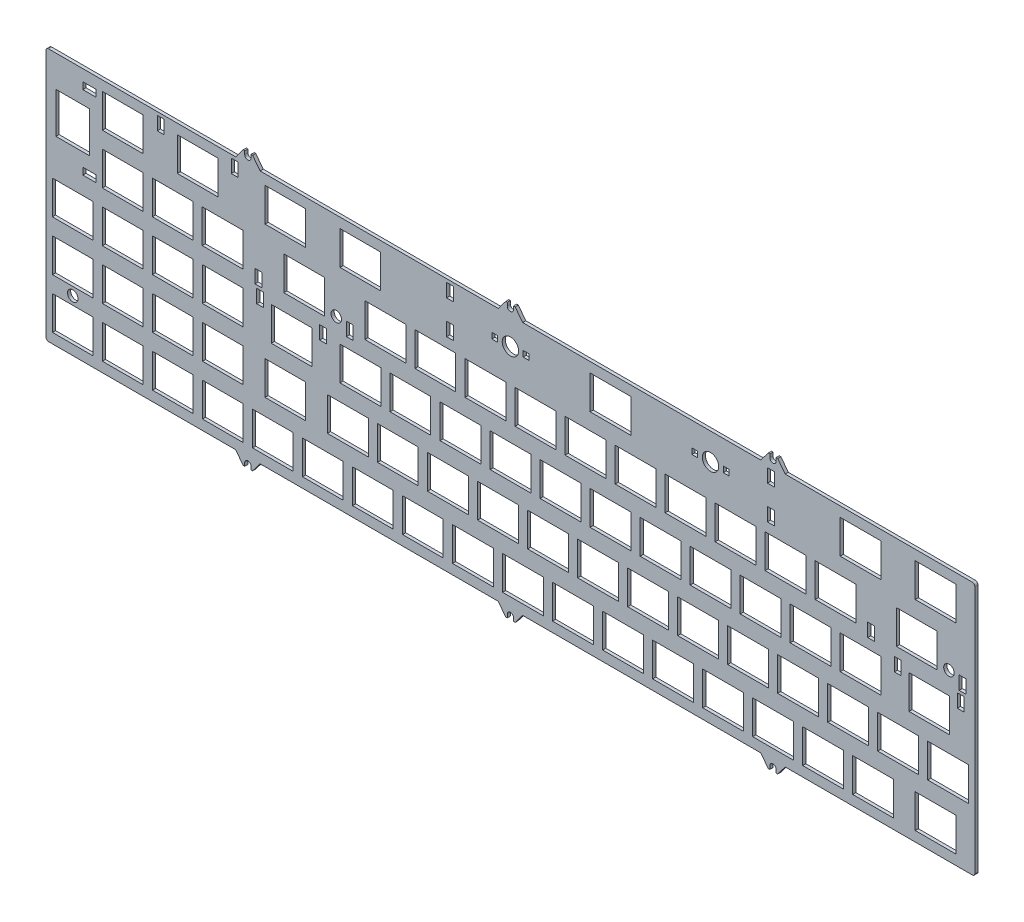
from build123d import *

# Parameters (mm, degrees)
SKETCH2_R           = 3.125
SKETCH2_R_2         = 2
SKETCH2_W           = 15.6
SKETCH2_H           = 12.8
SKETCH2_W_2         = 2.6
SKETCH2_H_2         = 5.1
SKETCH2_W_3         = 2.2
SKETCH2_H_3         = 2.2
SKETCH2_W_4         = 5.1
SKETCH2_H_4         = 2.6
SKETCH2_W_5         = 15.5
SKETCH2_W_6         = 12.8
SKETCH2_H_5         = 15.5
BOSS_EXTRUDE1_DEPTH = 1.2


with BuildPart() as part:
    # Sketch2 → Boss-Extrude1 (new body)
    with BuildSketch(Plane(origin=(0, 0, 0), x_dir=(1, 0, 0), z_dir=(0, 0, -1))):
        with BuildLine():
            Line((-4.122e-06, 4.749999815), (-4.122e-06, 99.349999815))
            ThreePointArc((-4.122e-06, 99.349999815), (0.292889097, 100.057106597), (0.999995878, 100.349999815))
            Line((0.999995878, 100.349999815), (72.237495878, 100.349999815))
            Line((72.237495878, 100.349999815), (75.087495878, 104.099999815))
            Line((75.087495878, 104.099999815), (75.687495878, 104.099999815))
            Line((75.687495878, 104.099999815), (75.687495878, 103.599999815))
            Line((75.687495878, 103.599999815), (75.687495878, 102.849999815))
            ThreePointArc((75.687495878, 102.849999815), (76.887495878, 101.649999815), (78.087495878, 102.849999815))
            Line((78.087495878, 102.849999815), (78.087495878, 103.599999815))
            Line((78.087495878, 103.599999815), (78.087495878, 104.099999815))
            Line((78.087495878, 104.099999815), (78.687495879, 104.099999815))
            Line((78.687495879, 104.099999815), (81.537495879, 100.349999815))
            Line((81.537495879, 100.349999815), (172.237495878, 100.349999815))
            Line((172.237495878, 100.349999815), (175.087495878, 104.099999815))
            Line((175.087495878, 104.099999815), (175.687495878, 104.099999815))
            Line((175.687495878, 104.099999815), (175.687495878, 102.849999815))
            ThreePointArc((175.687495878, 102.849999815), (176.887495878, 101.649999815), (178.087495878, 102.849999815))
            Line((178.087495878, 102.849999815), (178.087495878, 104.099999815))
            Line((178.087495878, 104.099999815), (178.687495878, 104.099999815))
            Line((178.687495878, 104.099999815), (181.537495878, 100.349999815))
            Line((181.537495878, 100.349999815), (272.237495878, 100.349999815))
            Line((272.237495878, 100.349999815), (275.087495878, 104.099999815))
            Line((275.087495878, 104.099999815), (275.687495878, 104.099999815))
            Line((275.687495878, 104.099999815), (275.687495878, 102.849999815))
            ThreePointArc((275.687495878, 102.849999815), (276.887495878, 101.649999815), (278.087495878, 102.849999815))
            Line((278.087495878, 102.849999815), (278.087495878, 104.099999815))
            Line((278.087495878, 104.099999815), (278.687495878, 104.099999815))
            Line((278.687495878, 104.099999815), (281.537495878, 100.349999815))
            Line((281.537495878, 100.349999815), (352.774995878, 100.349999815))
            ThreePointArc((352.774995878, 100.349999815), (353.48210266, 100.057106597), (353.774995878, 99.349999815))
            Line((353.774995878, 99.349999815), (353.774995878, 4.749999815))
            ThreePointArc((353.774995878, 4.749999815), (353.48210266, 4.042893034), (352.774995878, 3.749999815))
            Line((352.774995878, 3.749999815), (281.537495878, 3.749999815))
            Line((281.537495878, 3.749999815), (278.687495878, -1.85e-07))
            Line((278.687495878, -1.85e-07), (278.087495878, -1.85e-07))
            Line((278.087495878, -1.85e-07), (278.087495878, 1.249999815))
            ThreePointArc((278.087495878, 1.249999815), (276.887495878, 2.449999815), (275.687495878, 1.249999815))
            Line((275.687495878, 1.249999815), (275.687495878, -1.85e-07))
            Line((275.687495878, -1.85e-07), (275.087495878, -1.85e-07))
            Line((275.087495878, -1.85e-07), (272.237495878, 3.749999815))
            Line((272.237495878, 3.749999815), (181.537495878, 3.749999815))
            Line((181.537495878, 3.749999815), (178.687495878, -1.85e-07))
            Line((178.687495878, -1.85e-07), (178.087495878, -1.85e-07))
            Line((178.087495878, -1.85e-07), (178.087495878, 1.249999815))
            ThreePointArc((178.087495878, 1.249999815), (176.887495878, 2.449999815), (175.687495878, 1.249999815))
            Line((175.687495878, 1.249999815), (175.687495878, -1.85e-07))
            Line((175.687495878, -1.85e-07), (175.087495878, -1.85e-07))
            Line((175.087495878, -1.85e-07), (172.237495878, 3.749999815))
            Line((172.237495878, 3.749999815), (81.537495879, 3.749999815))
            Line((81.537495879, 3.749999815), (78.687495879, -1.85e-07))
            Line((78.687495879, -1.85e-07), (78.087495878, -1.85e-07))
            Line((78.087495878, -1.85e-07), (78.087495878, 0.499999815))
            Line((78.087495878, 0.499999815), (78.087495878, 1.249999815))
            ThreePointArc((78.087495878, 1.249999815), (76.887495878, 2.449999815), (75.687495878, 1.249999815))
            Line((75.687495878, 1.249999815), (75.687495878, 0.499999815))
            Line((75.687495878, 0.499999815), (75.687495878, -1.85e-07))
            Line((75.687495878, -1.85e-07), (75.087495878, -1.85e-07))
            Line((75.087495878, -1.85e-07), (72.237495878, 3.749999815))
            Line((72.237495878, 3.749999815), (0.999995878, 3.749999815))
            ThreePointArc((0.999995878, 3.749999815), (0.292889097, 4.042893034), (-4.122e-06, 4.749999815))
        make_face()
        with Locations((176.887495878, 13.949999815)):
            Circle(SKETCH2_R, mode=Mode.SUBTRACT)
        with Locations((253.087495878, 13.949999815)):
            Circle(SKETCH2_R, mode=Mode.SUBTRACT)
        with Locations((343.918745878, 37.249999815)):
            Circle(SKETCH2_R_2, mode=Mode.SUBTRACT)
        with Locations((110.556245878, 37.249999815)):
            Circle(SKETCH2_R_2, mode=Mode.SUBTRACT)
        with Locations((10.199995878, 80.624999815)):
            Circle(SKETCH2_R_2, mode=Mode.SUBTRACT)
        with Locations((129.262495878, 32.999999815)):
            Rectangle(SKETCH2_W, SKETCH2_H, mode=Mode.SUBTRACT)
        with Locations((119.737495878, 52.049999815)):
            Rectangle(SKETCH2_W, SKETCH2_H, mode=Mode.SUBTRACT)
        with Locations((114.974995878, 71.099999815)):
            Rectangle(SKETCH2_W, SKETCH2_H, mode=Mode.SUBTRACT)
        with Locations((324.431248691, 45.649999553)):
            Rectangle(SKETCH2_W_2, SKETCH2_H_2, mode=Mode.SUBTRACT)
        with Locations((348.431245878, 45.649999815)):
            Rectangle(SKETCH2_W_2, SKETCH2_H_2, mode=Mode.SUBTRACT)
        with Locations((105.543745878, 45.649999815)):
            Rectangle(SKETCH2_W_2, SKETCH2_H_2, mode=Mode.SUBTRACT)
        with Locations((314.268745878, 39.399999815)):
            Rectangle(SKETCH2_W_2, SKETCH2_H_2, mode=Mode.SUBTRACT)
        with Locations((349.068745878, 39.399999815)):
            Rectangle(SKETCH2_W_2, SKETCH2_H_2, mode=Mode.SUBTRACT)
        with Locations((115.706245878, 39.399999815)):
            Rectangle(SKETCH2_W_2, SKETCH2_H_2, mode=Mode.SUBTRACT)
        with Locations((153.887495878, 7.549999815)):
            Rectangle(SKETCH2_W_2, SKETCH2_H_2, mode=Mode.SUBTRACT)
        with Locations((182.862495878, 13.949999815)):
            Rectangle(SKETCH2_W_3, SKETCH2_H_3, mode=Mode.SUBTRACT)
        with Locations((170.912495878, 13.949999815)):
            Rectangle(SKETCH2_W_3, SKETCH2_H_3, mode=Mode.SUBTRACT)
        with Locations((247.112495878, 13.949999815)):
            Rectangle(SKETCH2_W_3, SKETCH2_H_3, mode=Mode.SUBTRACT)
        with Locations((259.062495878, 13.949999815)):
            Rectangle(SKETCH2_W_3, SKETCH2_H_3, mode=Mode.SUBTRACT)
        with Locations((81.543748691, 45.649999553)):
            Rectangle(SKETCH2_W_2, SKETCH2_H_2, mode=Mode.SUBTRACT)
        with Locations((80.906245878, 39.399999815)):
            Rectangle(SKETCH2_W_2, SKETCH2_H_2, mode=Mode.SUBTRACT)
        with Locations((43.674995878, 7.549999815)):
            Rectangle(SKETCH2_W_2, SKETCH2_H_2, mode=Mode.SUBTRACT)
        with Locations((71.874995878, 7.549999815)):
            Rectangle(SKETCH2_W_2, SKETCH2_H_2, mode=Mode.SUBTRACT)
        with Locations((16.574995878, 9.374999815)):
            Rectangle(SKETCH2_W_4, SKETCH2_H_4, mode=Mode.SUBTRACT)
        with Locations((16.574995878, 37.574999815)):
            Rectangle(SKETCH2_W_4, SKETCH2_H_4, mode=Mode.SUBTRACT)
        with Locations((153.887495878, 20.349999815)):
            Rectangle(SKETCH2_W_2, SKETCH2_H_2, mode=Mode.SUBTRACT)
        with Locations((276.087495878, 20.349999815)):
            Rectangle(SKETCH2_W_2, SKETCH2_H_2, mode=Mode.SUBTRACT)
        with Locations((276.087495878, 7.549999815)):
            Rectangle(SKETCH2_W_2, SKETCH2_H_2, mode=Mode.SUBTRACT)
        with Locations((338.812495878, 90.149999815)):
            Rectangle(SKETCH2_W_5, SKETCH2_H, mode=Mode.SUBTRACT)
        with Locations((314.999995878, 90.149999815)):
            Rectangle(SKETCH2_W_5, SKETCH2_H, mode=Mode.SUBTRACT)
        with Locations((295.949995878, 90.149999815)):
            Rectangle(SKETCH2_W_5, SKETCH2_H, mode=Mode.SUBTRACT)
        with Locations((276.899995878, 90.149999815)):
            Rectangle(SKETCH2_W_5, SKETCH2_H, mode=Mode.SUBTRACT)
        with Locations((257.849995878, 90.149999815)):
            Rectangle(SKETCH2_W_5, SKETCH2_H, mode=Mode.SUBTRACT)
        with Locations((238.799995878, 90.149999815)):
            Rectangle(SKETCH2_W_5, SKETCH2_H, mode=Mode.SUBTRACT)
        with Locations((219.749995878, 90.149999815)):
            Rectangle(SKETCH2_W_5, SKETCH2_H, mode=Mode.SUBTRACT)
        with Locations((200.699995878, 90.149999815)):
            Rectangle(SKETCH2_W_5, SKETCH2_H, mode=Mode.SUBTRACT)
        with Locations((181.649995878, 90.149999815)):
            Rectangle(SKETCH2_W_5, SKETCH2_H, mode=Mode.SUBTRACT)
        with Locations((162.599995878, 90.149999815)):
            Rectangle(SKETCH2_W_5, SKETCH2_H, mode=Mode.SUBTRACT)
        with Locations((143.549995878, 90.149999815)):
            Rectangle(SKETCH2_W_5, SKETCH2_H, mode=Mode.SUBTRACT)
        with Locations((124.499995878, 90.149999815)):
            Rectangle(SKETCH2_W_5, SKETCH2_H, mode=Mode.SUBTRACT)
        with Locations((105.449995878, 90.149999815)):
            Rectangle(SKETCH2_W_5, SKETCH2_H, mode=Mode.SUBTRACT)
        with Locations((86.399995878, 90.149999815)):
            Rectangle(SKETCH2_W_5, SKETCH2_H, mode=Mode.SUBTRACT)
        with Locations((67.349995878, 71.099999815)):
            Rectangle(SKETCH2_W_5, SKETCH2_H, mode=Mode.SUBTRACT)
        with Locations((67.349995878, 90.149999815)):
            Rectangle(SKETCH2_W_5, SKETCH2_H, mode=Mode.SUBTRACT)
        with Locations((48.299995878, 71.099999815)):
            Rectangle(SKETCH2_W_5, SKETCH2_H, mode=Mode.SUBTRACT)
        with Locations((48.299995878, 90.149999815)):
            Rectangle(SKETCH2_W_5, SKETCH2_H, mode=Mode.SUBTRACT)
        with Locations((29.249995878, 71.099999815)):
            Rectangle(SKETCH2_W_5, SKETCH2_H, mode=Mode.SUBTRACT)
        with Locations((29.249995878, 90.149999815)):
            Rectangle(SKETCH2_W_5, SKETCH2_H, mode=Mode.SUBTRACT)
        with Locations((10.199995878, 71.099999815)):
            Rectangle(SKETCH2_W_5, SKETCH2_H, mode=Mode.SUBTRACT)
        with Locations((10.199995878, 90.149999815)):
            Rectangle(SKETCH2_W_5, SKETCH2_H, mode=Mode.SUBTRACT)
        with Locations((67.299995878, 52.049999815)):
            Rectangle(SKETCH2_W_5, SKETCH2_H, mode=Mode.SUBTRACT)
        with Locations((48.249995878, 52.049999815)):
            Rectangle(SKETCH2_W_5, SKETCH2_H, mode=Mode.SUBTRACT)
        with Locations((29.199995878, 52.049999815)):
            Rectangle(SKETCH2_W_5, SKETCH2_H, mode=Mode.SUBTRACT)
        with Locations((10.149995878, 52.049999815)):
            Rectangle(SKETCH2_W_5, SKETCH2_H, mode=Mode.SUBTRACT)
        with Locations((48.249995878, 32.999999815)):
            Rectangle(SKETCH2_W_5, SKETCH2_H, mode=Mode.SUBTRACT)
        with Locations((29.199995878, 32.999999815)):
            Rectangle(SKETCH2_W_5, SKETCH2_H, mode=Mode.SUBTRACT)
        with Locations((29.199995878, 13.949999815)):
            Rectangle(SKETCH2_W_5, SKETCH2_H, mode=Mode.SUBTRACT)
        with Locations((57.774995878, 13.949999815)):
            Rectangle(SKETCH2_W_5, SKETCH2_H, mode=Mode.SUBTRACT)
        with Locations((91.162495878, 13.949999815)):
            Rectangle(SKETCH2_W_5, SKETCH2_H, mode=Mode.SUBTRACT)
        with Locations((119.737495878, 13.949999815)):
            Rectangle(SKETCH2_W_5, SKETCH2_H, mode=Mode.SUBTRACT)
        with Locations((98.306245878, 32.999999815)):
            Rectangle(SKETCH2_W_5, SKETCH2_H, mode=Mode.SUBTRACT)
        with Locations((93.543745878, 52.049999815)):
            Rectangle(SKETCH2_W_5, SKETCH2_H, mode=Mode.SUBTRACT)
        with Locations((91.162495878, 71.099999815)):
            Rectangle(SKETCH2_W_5, SKETCH2_H, mode=Mode.SUBTRACT)
        with Locations((336.431245878, 52.049999815)):
            Rectangle(SKETCH2_W_5, SKETCH2_H, mode=Mode.SUBTRACT)
        with Locations((214.987495878, 13.949999815)):
            Rectangle(SKETCH2_W_5, SKETCH2_H, mode=Mode.SUBTRACT)
        with Locations((310.237495879, 13.949999815)):
            Rectangle(SKETCH2_W_5, SKETCH2_H, mode=Mode.SUBTRACT)
        with Locations((331.668745878, 32.999999815)):
            Rectangle(SKETCH2_W_5, SKETCH2_H, mode=Mode.SUBTRACT)
        with Locations((338.812495879, 13.949999815)):
            Rectangle(SKETCH2_W_5, SKETCH2_H, mode=Mode.SUBTRACT)
        with Locations((10.174995878, 23.474999815)):
            Rectangle(SKETCH2_W_6, SKETCH2_H_5, mode=Mode.SUBTRACT)
        with Locations((286.424995878, 71.099999815)):
            Rectangle(SKETCH2_W_5, SKETCH2_H, mode=Mode.SUBTRACT)
        with Locations((267.374995878, 71.099999815)):
            Rectangle(SKETCH2_W_5, SKETCH2_H, mode=Mode.SUBTRACT)
        with Locations((248.324995878, 71.099999815)):
            Rectangle(SKETCH2_W_5, SKETCH2_H, mode=Mode.SUBTRACT)
        with Locations((229.274995878, 71.099999815)):
            Rectangle(SKETCH2_W_5, SKETCH2_H, mode=Mode.SUBTRACT)
        with Locations((210.224995878, 71.099999815)):
            Rectangle(SKETCH2_W_5, SKETCH2_H, mode=Mode.SUBTRACT)
        with Locations((191.174995878, 71.099999815)):
            Rectangle(SKETCH2_W_5, SKETCH2_H, mode=Mode.SUBTRACT)
        with Locations((172.124995878, 71.099999815)):
            Rectangle(SKETCH2_W_5, SKETCH2_H, mode=Mode.SUBTRACT)
        with Locations((153.074995878, 71.099999815)):
            Rectangle(SKETCH2_W_5, SKETCH2_H, mode=Mode.SUBTRACT)
        with Locations((134.024995878, 71.099999815)):
            Rectangle(SKETCH2_W_5, SKETCH2_H, mode=Mode.SUBTRACT)
        with Locations((291.187495878, 52.049999815)):
            Rectangle(SKETCH2_W_5, SKETCH2_H, mode=Mode.SUBTRACT)
        with Locations((272.137495878, 52.049999815)):
            Rectangle(SKETCH2_W_5, SKETCH2_H, mode=Mode.SUBTRACT)
        with Locations((253.087495878, 52.049999815)):
            Rectangle(SKETCH2_W_5, SKETCH2_H, mode=Mode.SUBTRACT)
        with Locations((234.037495878, 52.049999815)):
            Rectangle(SKETCH2_W_5, SKETCH2_H, mode=Mode.SUBTRACT)
        with Locations((214.987495878, 52.049999815)):
            Rectangle(SKETCH2_W_5, SKETCH2_H, mode=Mode.SUBTRACT)
        with Locations((195.937495878, 52.049999815)):
            Rectangle(SKETCH2_W_5, SKETCH2_H, mode=Mode.SUBTRACT)
        with Locations((176.887495878, 52.049999815)):
            Rectangle(SKETCH2_W_5, SKETCH2_H, mode=Mode.SUBTRACT)
        with Locations((157.837495878, 52.049999815)):
            Rectangle(SKETCH2_W_5, SKETCH2_H, mode=Mode.SUBTRACT)
        with Locations((138.787495878, 52.049999815)):
            Rectangle(SKETCH2_W_5, SKETCH2_H, mode=Mode.SUBTRACT)
        with Locations((300.712495878, 32.999999815)):
            Rectangle(SKETCH2_W_5, SKETCH2_H, mode=Mode.SUBTRACT)
        with Locations((281.662495878, 32.999999815)):
            Rectangle(SKETCH2_W_5, SKETCH2_H, mode=Mode.SUBTRACT)
        with Locations((262.612495878, 32.999999815)):
            Rectangle(SKETCH2_W_5, SKETCH2_H, mode=Mode.SUBTRACT)
        with Locations((243.562495878, 32.999999815)):
            Rectangle(SKETCH2_W_5, SKETCH2_H, mode=Mode.SUBTRACT)
        with Locations((224.512495878, 32.999999815)):
            Rectangle(SKETCH2_W_5, SKETCH2_H, mode=Mode.SUBTRACT)
        with Locations((205.462495878, 32.999999815)):
            Rectangle(SKETCH2_W_5, SKETCH2_H, mode=Mode.SUBTRACT)
        with Locations((186.412495878, 32.999999815)):
            Rectangle(SKETCH2_W_5, SKETCH2_H, mode=Mode.SUBTRACT)
        with Locations((167.362495878, 32.999999815)):
            Rectangle(SKETCH2_W_5, SKETCH2_H, mode=Mode.SUBTRACT)
        with Locations((148.312495878, 32.999999815)):
            Rectangle(SKETCH2_W_5, SKETCH2_H, mode=Mode.SUBTRACT)
        with Locations((343.574995878, 71.099999815)):
            Rectangle(SKETCH2_W_5, SKETCH2_H, mode=Mode.SUBTRACT)
        with Locations((324.524995878, 71.099999815)):
            Rectangle(SKETCH2_W_5, SKETCH2_H, mode=Mode.SUBTRACT)
        with Locations((305.474995878, 71.099999815)):
            Rectangle(SKETCH2_W_5, SKETCH2_H, mode=Mode.SUBTRACT)
        with Locations((310.237495878, 52.049999815)):
            Rectangle(SKETCH2_W_5, SKETCH2_H, mode=Mode.SUBTRACT)
        with Locations((67.249995878, 32.999999815)):
            Rectangle(SKETCH2_W_5, SKETCH2_H, mode=Mode.SUBTRACT)
    extrude(amount=-BOSS_EXTRUDE1_DEPTH)


solid = part.part
